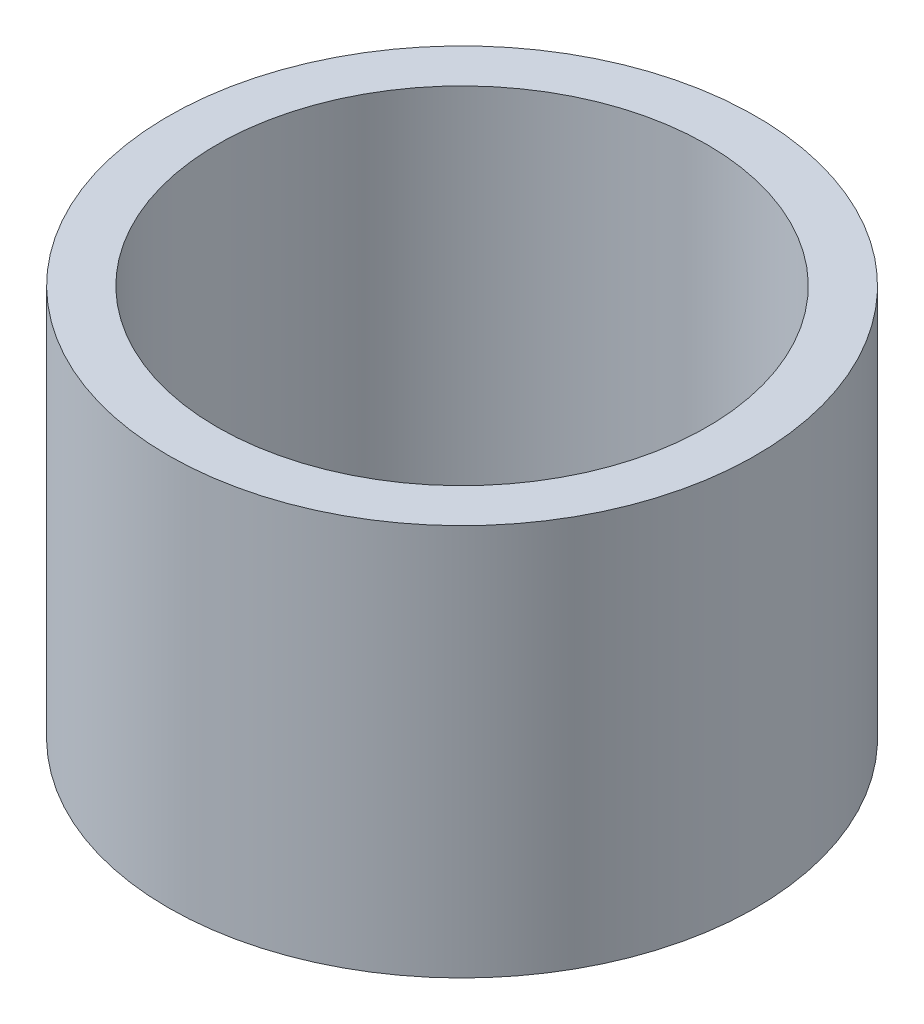
from build123d import *

# Parameters (mm, degrees)
SKETCH1_R           = 0.3
SKETCH1_R_2         = 0.25
BOSS_EXTRUDE1_DEPTH = 0.4


with BuildPart() as part:
    # Sketch1 → Boss-Extrude1 (new body)
    with BuildSketch(Plane(origin=(0, 0, 0), x_dir=(1, 0, 0), z_dir=(0, 1, 0))):
        Circle(SKETCH1_R)
        Circle(SKETCH1_R_2, mode=Mode.SUBTRACT)
    extrude(amount=BOSS_EXTRUDE1_DEPTH)


solid = part.part
